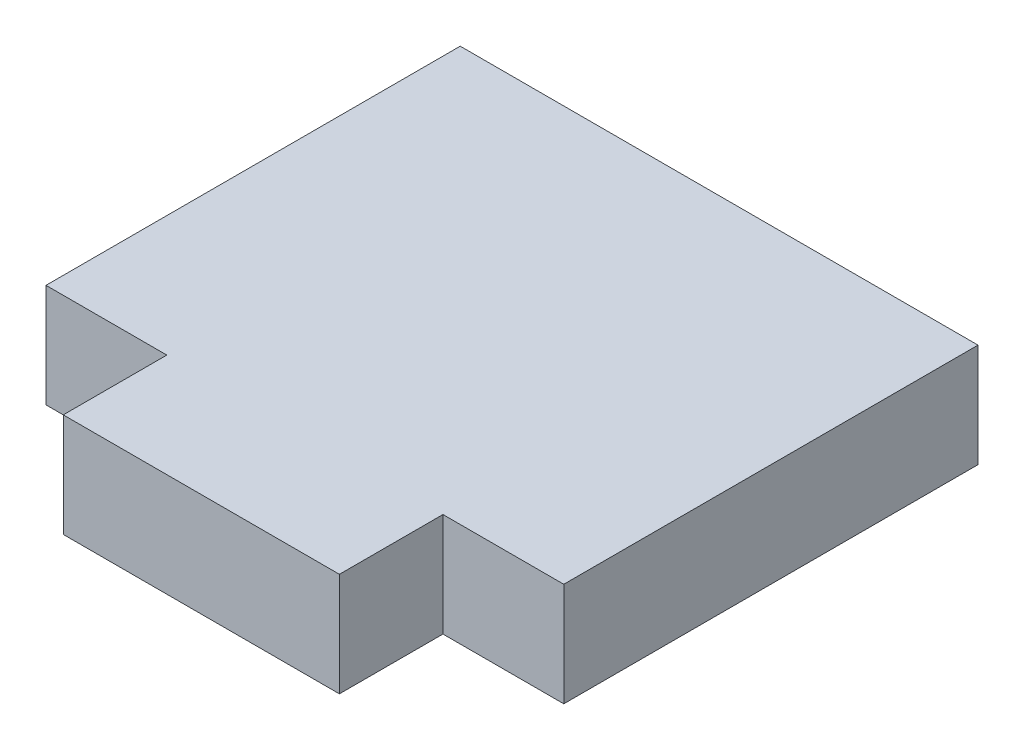
from build123d import *

# Parameters (mm, degrees)
SKETCH6_W           = 15
SKETCH6_H           = 12
BOSS_EXTRUDE4_DEPTH = 1.5
SKETCH8_W           = 8
SKETCH8_H           = 3
BOSS_EXTRUDE5_DEPTH = 1.5


with BuildPart() as part:
    # Sketch6 → Boss-Extrude4 (new body, symmetric)
    with BuildSketch(Plane(origin=(0, 0, 0), x_dir=(1, 0, 0), z_dir=(0, 1, 0))):
        Rectangle(SKETCH6_W, SKETCH6_H)
    extrude(amount=BOSS_EXTRUDE4_DEPTH, both=True)

    # Sketch8 → Boss-Extrude5 (add, symmetric)
    with BuildSketch(Plane(origin=(0, 0, 0), x_dir=(1, 0, 0), z_dir=(0, 1, 0))):
        with Locations((0, -7.5)):
            Rectangle(SKETCH8_W, SKETCH8_H)
    extrude(amount=BOSS_EXTRUDE5_DEPTH, both=True)


solid = part.part
